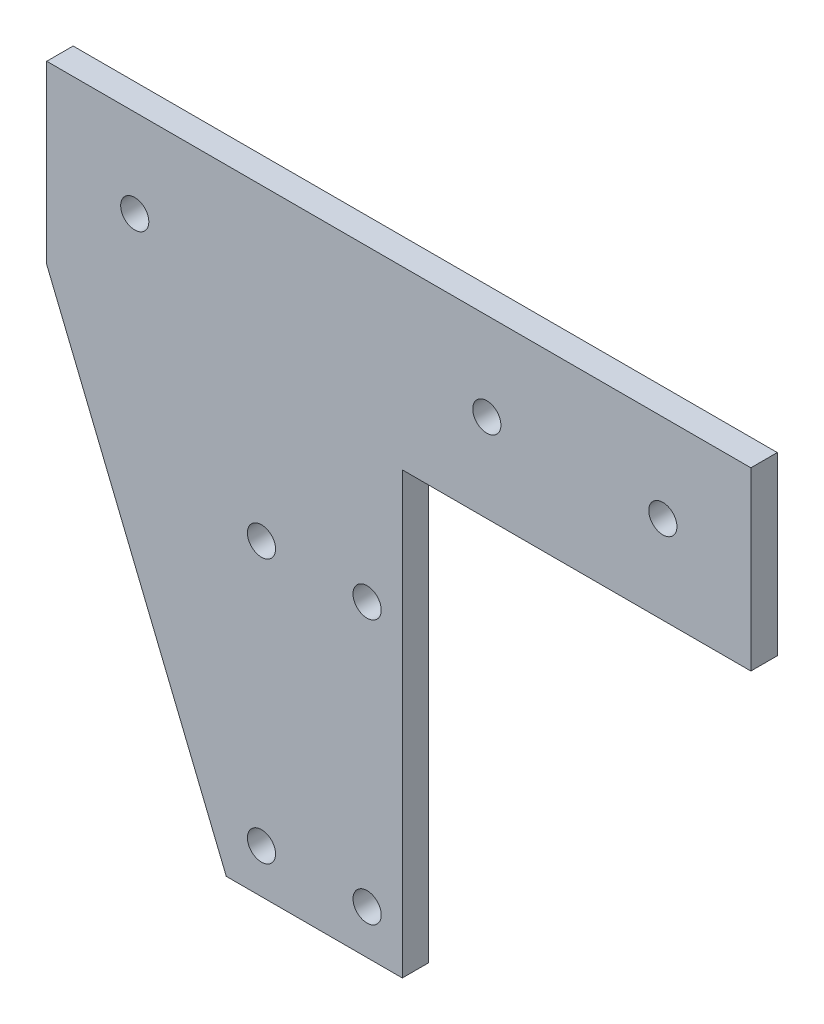
from build123d import *

# Parameters (mm, degrees)
SKETCH1_R      = 1.6
EXTRUDE1_DEPTH = 3


with BuildPart() as part:
    # Sketch1 → Extrude1 (new body)
    with BuildSketch(Plane.XY):
        Polygon((-182.858183995, 20), (-182.858183995, 0), (-162.458183995, -50), (-142.458183995, -50), (-142.458183995, 0), (-111.142455243, 0), (-102.858183995, 0), (-102.858183995, 20), align=None)
        with Locations((-172.858183995, 10)):
            Circle(SKETCH1_R, mode=Mode.SUBTRACT)
        with Locations((-112.858183995, 10)):
            Circle(SKETCH1_R, mode=Mode.SUBTRACT)
        with Locations((-132.858183995, 10)):
            Circle(SKETCH1_R, mode=Mode.SUBTRACT)
        with Locations((-158.458183995, -15)):
            Circle(SKETCH1_R, mode=Mode.SUBTRACT)
        with Locations((-146.458183995, -15)):
            Circle(SKETCH1_R, mode=Mode.SUBTRACT)
        with Locations((-158.458183995, -45)):
            Circle(SKETCH1_R, mode=Mode.SUBTRACT)
        with Locations((-146.458183995, -45)):
            Circle(SKETCH1_R, mode=Mode.SUBTRACT)
    extrude(amount=EXTRUDE1_DEPTH)


solid = part.part
